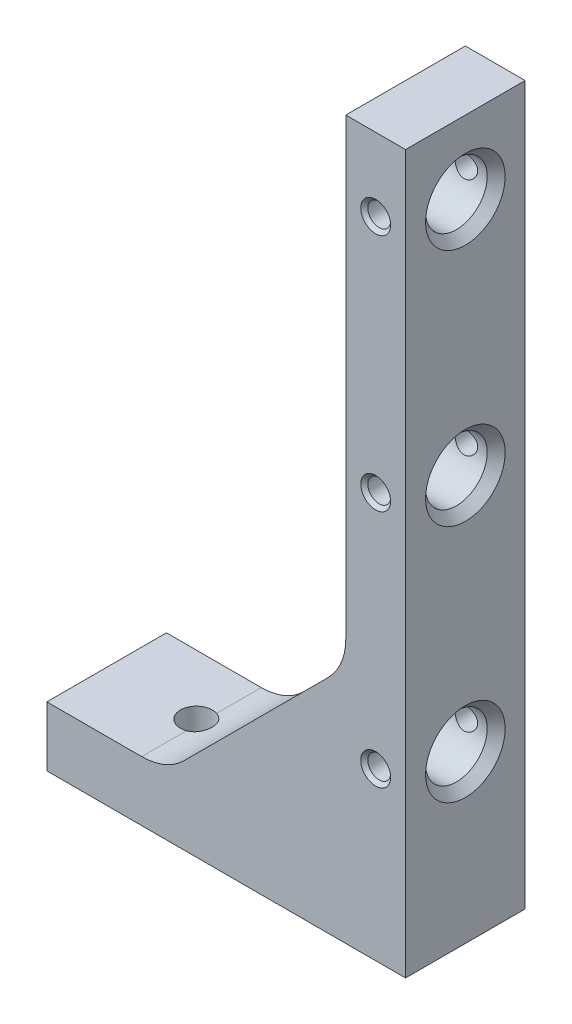
from build123d import *

# Parameters (mm, degrees)
BOSS_EXTRUDE1_DEPTH                       = 25.4
TAPPED_HOLE_FOR_1_4_20_HELICOIL1_D        = 6.7564
TAPPED_HOLE_FOR_1_4_20_HELICOIL1_DEPTH    = 20.5232
TAPPED_HOLE_FOR_1_4_20_HELICOIL1_TIP      = 2.029827343
F_33_64_0_51563_DIAMETER_HOLE1_AT_2_COUNT = 2
F_33_64_0_51563_DIAMETER_HOLE1_AT_2_PITCH = 50.8
F_33_64_0_51563_DIAMETER_HOLE1_AT_3_COUNT = 2
F_33_64_0_51563_DIAMETER_HOLE1_AT_3_PITCH = 50.8
F_11_0_191_DIAMETER_HOLE1_AT_2_COUNT      = 2
F_11_0_191_DIAMETER_HOLE1_AT_2_PITCH      = 50.8
F_11_0_191_DIAMETER_HOLE1_AT_3_COUNT      = 2
F_11_0_191_DIAMETER_HOLE1_AT_3_PITCH      = 50.8


with BuildPart() as part:
    # Sketch1 → Boss-Extrude1 (new body)
    with BuildSketch(Plane.XY):
        with BuildLine():
            Line((0, 0), (0, 12.7))
            Line((0, 12.7), (20.139487758, 12.7))
            ThreePointArc((20.139487758, 12.7), (24.999567349, 13.666729937), (29.119743879, 16.419743879))
            Line((29.119743879, 16.419743879), (59.780256121, 47.080256121))
            ThreePointArc((59.780256121, 47.080256121), (62.533270063, 51.200432651), (63.5, 56.060512242))
            Line((63.5, 56.060512242), (63.5, 152.4))
            Line((63.5, 152.4), (76.2, 152.4))
            Line((76.2, 152.4), (76.2, 0))
            Line((76.2, 0), (0, 0))
        make_face()
    extrude(amount=BOSS_EXTRUDE1_DEPTH)

    # Tapped Hole for 1/4-20 Helicoil1
    with Locations(Plane.XZ):
        with Locations((19.05, 12.7), (50.8, 12.7)):
            Hole(TAPPED_HOLE_FOR_1_4_20_HELICOIL1_D / 2, depth=TAPPED_HOLE_FOR_1_4_20_HELICOIL1_DEPTH)
            with Locations((0, 0, -(TAPPED_HOLE_FOR_1_4_20_HELICOIL1_DEPTH + TAPPED_HOLE_FOR_1_4_20_HELICOIL1_TIP / 2))):  # 118° drill point
                Cone(0, TAPPED_HOLE_FOR_1_4_20_HELICOIL1_D / 2, TAPPED_HOLE_FOR_1_4_20_HELICOIL1_TIP, mode=Mode.SUBTRACT)

    # Sketch5 → 33/64 (0.51563) Diameter Hole1 (revolve, cut)
    with BuildSketch(Plane(origin=(0, 86.106, 12.7), x_dir=(0, 0, 1), z_dir=(0, 1, 0))):
        Polygon((0, 0), (0, 76.2), (8.453501, 76.2), (6.548501, 74.295), (6.548501, 0), align=None)
    f_33_64_0_51563_diameter_hole1 = revolve(axis=Axis((-6.35, 86.106, 12.7), (1, 0, 0)), mode=Mode.SUBTRACT)

    # 33/64 (0.51563) Diameter Hole1 at 2: 33/64 (0.51563) Diameter Hole1 ×2
    with Locations(*[(0, i * F_33_64_0_51563_DIAMETER_HOLE1_AT_2_PITCH, 0) for i in range(1, F_33_64_0_51563_DIAMETER_HOLE1_AT_2_COUNT)]):
        add(f_33_64_0_51563_diameter_hole1, mode=Mode.SUBTRACT)

    # 33/64 (0.51563) Diameter Hole1 at 3: 33/64 (0.51563) Diameter Hole1 ×2
    with Locations(*[(0, -i * F_33_64_0_51563_DIAMETER_HOLE1_AT_3_PITCH, 0) for i in range(1, F_33_64_0_51563_DIAMETER_HOLE1_AT_3_COUNT)]):
        add(f_33_64_0_51563_diameter_hole1, mode=Mode.SUBTRACT)

    # Sketch7 → #11 (0.191) Diameter Hole1 (revolve, cut)
    with BuildSketch(Plane(origin=(69.85, 86.106, 25.4), x_dir=(0, -1, 0), z_dir=(1, 0, 0))):
        Polygon((0, 0), (0, 25.4), (3.175, 25.4), (2.4257, 24.6507), (2.4257, 0.7493), (3.175, 0), align=None)
    f_11_0_191_diameter_hole1 = revolve(axis=Axis((69.85, 86.106, 31.75), (0, 0, -1)), mode=Mode.SUBTRACT)

    # #11 (0.191) Diameter Hole1 at 2: #11 (0.191) Diameter Hole1 ×2
    with Locations(*[(0, i * F_11_0_191_DIAMETER_HOLE1_AT_2_PITCH, 0) for i in range(1, F_11_0_191_DIAMETER_HOLE1_AT_2_COUNT)]):
        add(f_11_0_191_diameter_hole1, mode=Mode.SUBTRACT)

    # #11 (0.191) Diameter Hole1 at 3: #11 (0.191) Diameter Hole1 ×2
    with Locations(*[(0, -i * F_11_0_191_DIAMETER_HOLE1_AT_3_PITCH, 0) for i in range(1, F_11_0_191_DIAMETER_HOLE1_AT_3_COUNT)]):
        add(f_11_0_191_diameter_hole1, mode=Mode.SUBTRACT)


solid = part.part
